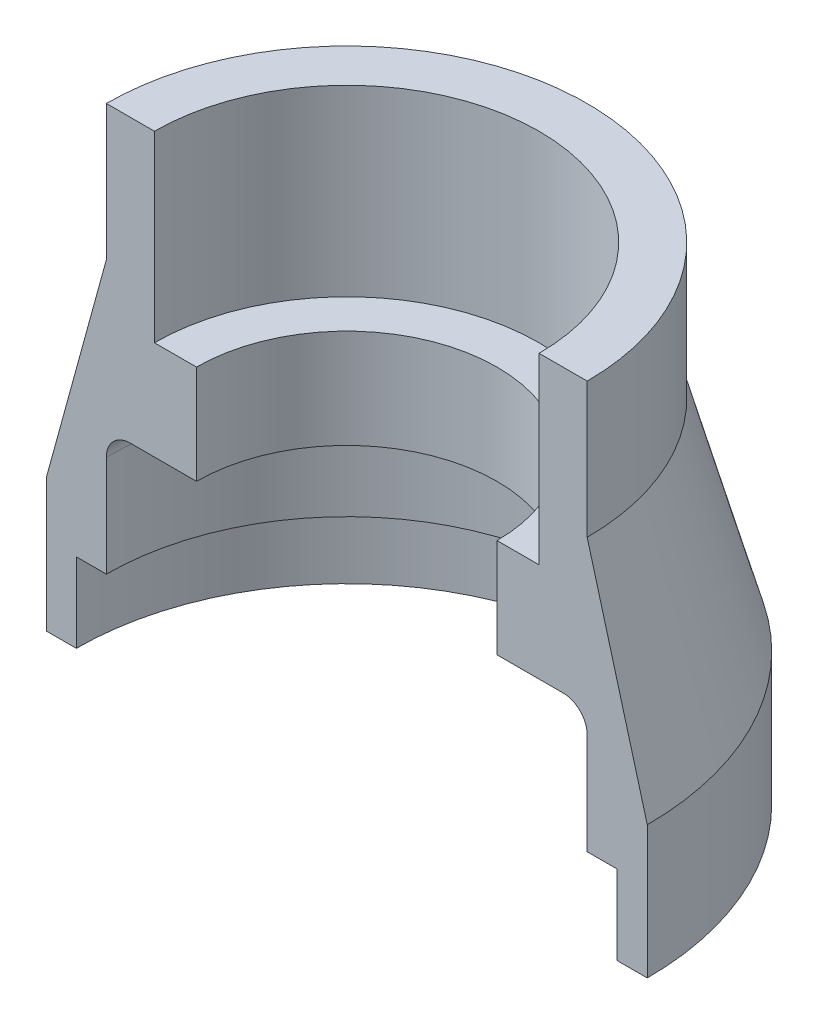
from build123d import *

# Parameters (mm, degrees)
SKETCH3_W          = 71.408394521
SKETCH3_H          = 27.275546844
CUT_EXTRUDE2_DEPTH = 100


with BuildPart() as part:
    # Sketch1 → Revolve1 (revolve)
    with BuildSketch(Plane.XY, mode=Mode.PRIVATE) as revolve1_sk:
        with BuildLine():
            Line((16, 32.849548789), (16, 17.609057399))
            Line((16, 17.609057399), (12.5, 17.609057399))
            Line((12.5, 17.609057399), (12.5, 9.374527929))
            Line((12.5, 9.374527929), (18, 9.374527929))
            ThreePointArc((18, 9.374527929), (19.414213562, 8.788741491), (20, 7.374527929))
            Line((20, 7.374527929), (20, -1.061426296))
            Line((20, -1.061426296), (22.5, -1.061426296))
            Line((22.5, -1.061426296), (22.5, -7.65813411))
            Line((22.5, -7.65813411), (25, -7.65813411))
            Line((25, -7.65813411), (25, 3.380682237))
            Line((25, 3.380682237), (20, 21.59503207))
            Line((20, 21.59503207), (20, 32.849548789))
            Line((20, 32.849548789), (16, 32.849548789))
        make_face()
    revolve(revolve1_sk.sketch.rotate(Axis((0, 89.637369386, 0), (0, -1, 0)), 90), axis=Axis((0, 89.637369386, 0), (0, -1, 0)))  # turned: the seam where the file's is

    # Sketch3 → Cut-Extrude2 (cut, symmetric)
    with BuildSketch(Plane(origin=(0, 0, 0), x_dir=(1, 0, 0), z_dir=(0, 1, 0))):
        with Locations((-0.506442515, -13.637773422)):
            Rectangle(SKETCH3_W, SKETCH3_H)
    extrude(amount=CUT_EXTRUDE2_DEPTH, both=True, mode=Mode.SUBTRACT)


solid = part.part
